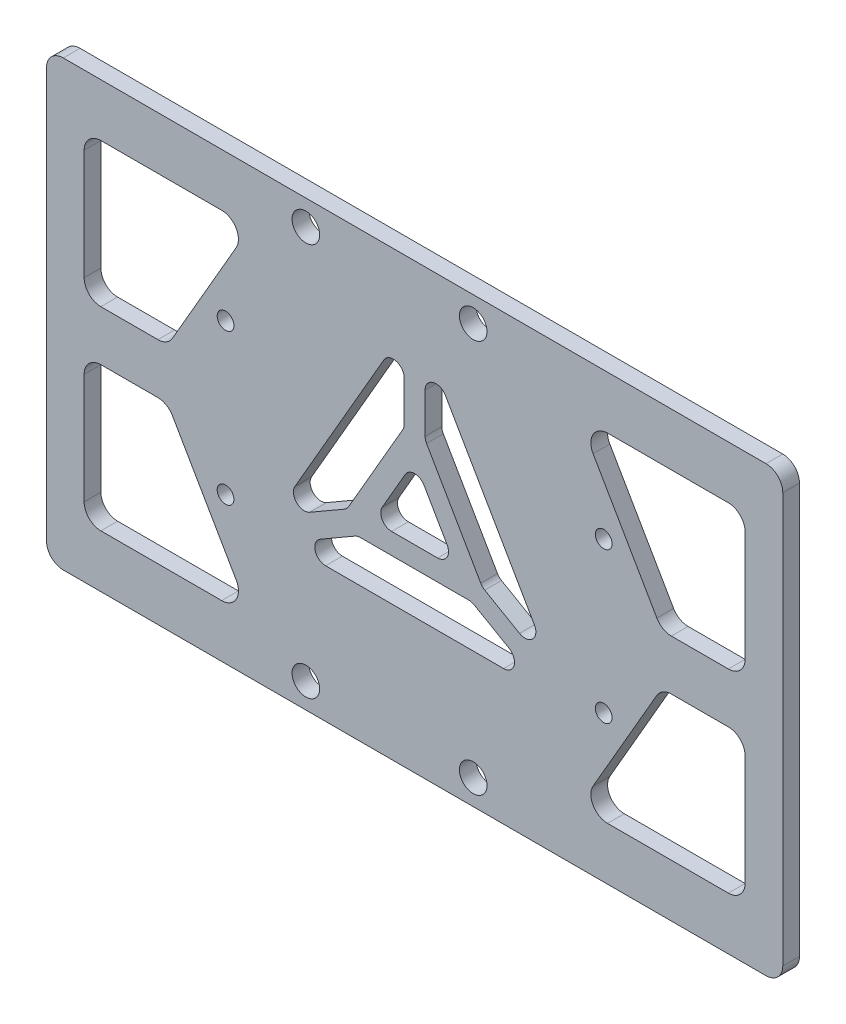
from build123d import *

# Parameters (mm, degrees)
SKETCH_1_W          = 88
SKETCH_1_H          = 53
EXTRUDE_1_DEPTH     = 2
SKETCH_2_R          = 1.65
SKETCH_2_R_2        = 1
CUT_EXTRUDE_1_DEPTH = 10
CUT_EXTRUDE_2_DEPTH = 10
FILLET_1_R          = 1.3
FILLET_4_R          = 2
CUT_EXTRUDE_6_DEPTH = 10
FILLET_5_R          = 2


with BuildPart() as part:
    # 草图1 → 凸台-拉伸1 (new body)
    with BuildSketch(Plane.XY):
        Rectangle(SKETCH_1_W, SKETCH_1_H)
    extrude(amount=EXTRUDE_1_DEPTH)

    # 草图2 → 切除-拉伸1 (cut)
    with BuildSketch(Plane.XY.offset(2)):
        with Locations((7, -23.5)):
            Circle(SKETCH_2_R)
        with Locations((-13, -23.5)):
            Circle(SKETCH_2_R)
        with Locations((-13, 23.5)):
            Circle(SKETCH_2_R)
        with Locations((7, 23.5)):
            Circle(SKETCH_2_R)
        with Locations((22.6, 9)):
            Circle(SKETCH_2_R_2)
        with Locations((22.6, -9)):
            Circle(SKETCH_2_R_2)
        with Locations((-22.6, -9)):
            Circle(SKETCH_2_R_2)
        with Locations((-22.6, 9)):
            Circle(SKETCH_2_R_2)
    extrude(amount=-CUT_EXTRUDE_1_DEPTH, mode=Mode.SUBTRACT)

    # 草图3 → 切除-拉伸2 (cut)
    with BuildSketch(Plane.XY.offset(2)):
        Polygon((0, 5.773502692), (-5, -2.886751346), (5, -2.886751346), align=None)
        Polygon((1.25, 8.608439182), (1.25, 18.608439182), (16.740381057, -8.221687836), (8.080127019, -3.221687836), align=None)
        Polygon((-6.830127019, -5.386751346), (6.830127019, -5.386751346), (15.490381057, -10.386751346), (-15.490381057, -10.386751346), align=None)
        Polygon((-1.25, 8.608439182), (-8.080127019, -3.221687836), (-16.740381057, -8.221687836), (-1.25, 18.608439182), align=None)
    extrude(amount=-CUT_EXTRUDE_2_DEPTH, mode=Mode.SUBTRACT)

    # 圆角1
    fillet_1_edges = [part.edges().sort_by_distance(p)[0] for p in [
        (6.830127019, -5.386751346, 1),
        (15.490381057, -10.386751346, 1),
        (-15.490381057, -10.386751346, 1),
        (-6.830127019, -5.386751346, 1),
        (8.080127019, -3.221687836, 1),
        (1.25, 8.608439182, 1),
        (1.25, 18.608439182, 1),
        (16.740381057, -8.221687836, 1),
        (-8.080127019, -3.221687836, 1),
        (-16.740381057, -8.221687836, 1),
        (-1.25, 18.608439182, 1),
        (-1.25, 8.608439182, 1),
        (5, -2.886751346, 1),
        (-5, -2.886751346, 1),
        (0, 5.773502692, 1),
    ]]
    fillet(fillet_1_edges, radius=FILLET_1_R)

    # 圆角4
    fillet_4_edges = [part.edges().sort_by_distance(p)[0] for p in [
        (44, -26.5, 1),
        (-44, -26.5, 1),
        (-44, 26.5, 1),
        (44, 26.5, 1),
    ]]
    fillet(fillet_4_edges, radius=FILLET_4_R)

    # 草图7 → 切除-拉伸6 (cut)
    with BuildSketch(Plane.XY.offset(2)):
        Polygon((19.5977786, 20.2), (39.5, 20.2), (39.5, 3), (29.52820323, 3), align=None)
        Polygon((29.52820323, -3), (19.5977786, -20.2), (39.5, -20.2), (39.5, -3), align=None)
        Polygon((-39.5, -3), (-29.52820323, -3), (-19.5977786, -20.2), (-39.5, -20.2), align=None)
        Polygon((-39.5, 3), (-29.52820323, 3), (-19.5977786, 20.2), (-39.5, 20.2), align=None)
    extrude(amount=-CUT_EXTRUDE_6_DEPTH, mode=Mode.SUBTRACT)

    # 圆角5
    fillet_5_edges = [part.edges().sort_by_distance(p)[0] for p in [
        (-39.5, 3, 1),
        (-39.5, 20.2, 1),
        (-19.5977786, 20.2, 1),
        (-29.52820323, 3, 1),
        (29.52820323, -3, 1),
        (39.5, -3, 1),
        (39.5, -20.2, 1),
        (19.5977786, -20.2, 1),
        (-39.5, -20.2, 1),
        (-39.5, -3, 1),
        (-29.52820323, -3, 1),
        (-19.5977786, -20.2, 1),
        (29.52820323, 3, 1),
        (19.5977786, 20.2, 1),
        (39.5, 20.2, 1),
        (39.5, 3, 1),
    ]]
    fillet(fillet_5_edges, radius=FILLET_5_R)


solid = part.part
